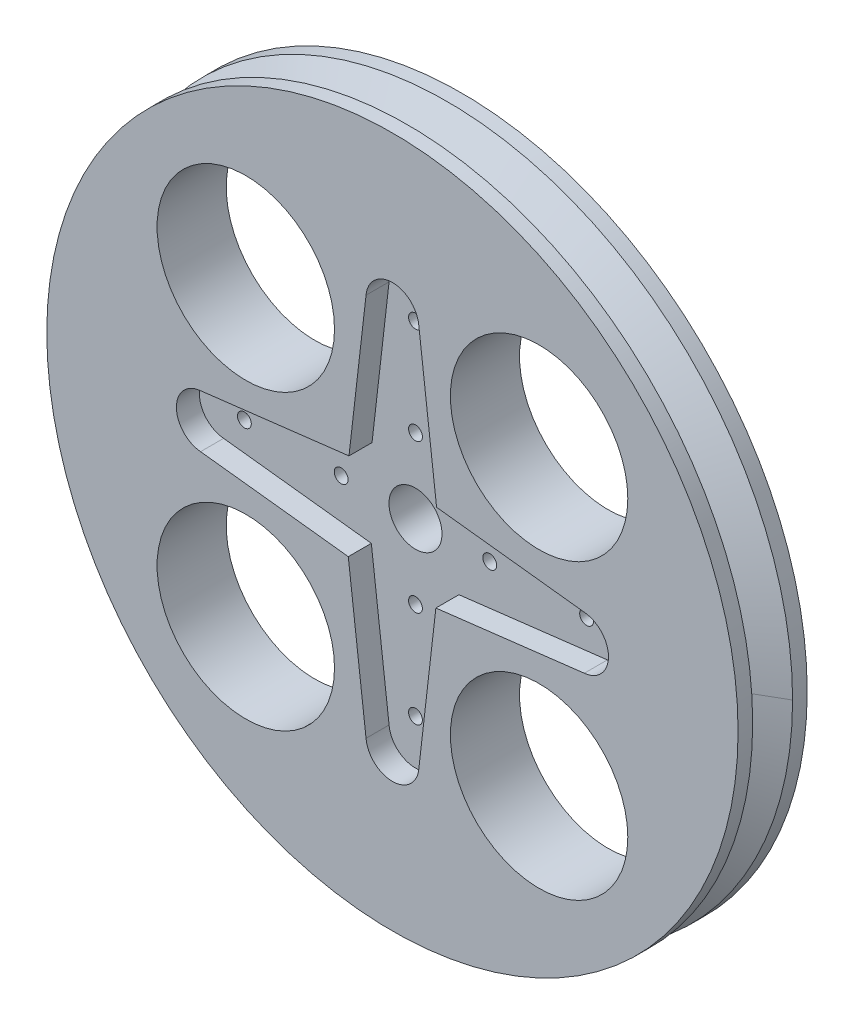
from build123d import *

# Parameters (mm, degrees)
SKETCH1_R           = 30
SKETCH1_R_2         = 7.7
SKETCH1_R_3         = 2.3
SKETCH1_R_4         = 0.6
BOSS_EXTRUDE1_DEPTH = 6
CUT_EXTRUDE1_DEPTH  = 2


with BuildPart() as part:
    # Sketch1 → Boss-Extrude1 (new body)
    with BuildSketch(Plane.XY):
        Circle(SKETCH1_R)
        with Locations((-12.727922061, 12.727922061)):
            Circle(SKETCH1_R_2, mode=Mode.SUBTRACT)
        with Locations((12.727922061, 12.727922061)):
            Circle(SKETCH1_R_2, mode=Mode.SUBTRACT)
        with Locations((12.727922061, -12.727922061)):
            Circle(SKETCH1_R_2, mode=Mode.SUBTRACT)
        with Locations((-12.727922061, -12.727922061)):
            Circle(SKETCH1_R_2, mode=Mode.SUBTRACT)
        Circle(SKETCH1_R_3, mode=Mode.SUBTRACT)
        with Locations((-14.85, 0)):
            Circle(SKETCH1_R_4, mode=Mode.SUBTRACT)
        with Locations((6.45, 0)):
            Circle(SKETCH1_R_4, mode=Mode.SUBTRACT)
        with Locations((0, -6.45)):
            Circle(SKETCH1_R_4, mode=Mode.SUBTRACT)
        with Locations((-6.45, 0)):
            Circle(SKETCH1_R_4, mode=Mode.SUBTRACT)
        with Locations((0, 6.45)):
            Circle(SKETCH1_R_4, mode=Mode.SUBTRACT)
        with Locations((0, 14.85)):
            Circle(SKETCH1_R_4, mode=Mode.SUBTRACT)
        with Locations((14.85, 0)):
            Circle(SKETCH1_R_4, mode=Mode.SUBTRACT)
        with Locations((0, -14.85)):
            Circle(SKETCH1_R_4, mode=Mode.SUBTRACT)
    extrude(amount=-BOSS_EXTRUDE1_DEPTH)

    # Cut-Sweep1: sweep along a curve in space
    with BuildLine() as cut_sweep1_path:
        ThreePointArc((30, 0, -6), (21.213203436, 21.213203436, -6), (0, 30, -6))
        ThreePointArc((0, 30, -6), (-21.213203436, 21.213203436, -6), (-30, 0, -6))
        ThreePointArc((-30, 0, -6), (-21.213203436, -21.213203436, -6), (0, -30, -6))
        ThreePointArc((0, -30, -6), (21.213203436, -21.213203436, -6), (30, 0, -6))
    # Sketch2 → Cut-Sweep1 (sweep, cut)
    with BuildSketch(Plane(origin=(0, 0, 0), x_dir=(1, 0, 0), z_dir=(0, 1, 0))):
        Polygon((-31.156921938, 0.6), (-27, 3), (-31.156921938, 5.4), align=None)
    sweep(path=cut_sweep1_path.line, mode=Mode.SUBTRACT)

    # Sketch4 → Cut-Extrude1 (cut)
    with BuildSketch(Plane.XY):
        with BuildLine():
            Line((-3.770723751, 3.831893278), (-16.652735562, 2.291047422))
            ThreePointArc((-16.652735562, 2.291047422), (-18.75, 0), (-16.652735562, -2.291047422))
            Line((-16.652735562, -2.291047422), (-3.831893278, -3.770723751))
            Line((-3.831893278, -3.770723751), (-2.291047422, -16.652735562))
            ThreePointArc((-2.291047422, -16.652735562), (0, -18.75), (2.291047422, -16.652735562))
            Line((2.291047422, -16.652735562), (3.770723751, -3.831893278))
            Line((3.770723751, -3.831893278), (16.652735562, -2.291047422))
            ThreePointArc((16.652735562, -2.291047422), (18.75, 0), (16.652735562, 2.291047422))
            Line((16.652735562, 2.291047422), (3.831893278, 3.770723751))
            Line((3.831893278, 3.770723751), (2.291047422, 16.652735562))
            ThreePointArc((2.291047422, 16.652735562), (0, 18.75), (-2.291047422, 16.652735562))
            Line((-2.291047422, 16.652735562), (-3.770723751, 3.831893278))
        make_face()
    extrude(amount=-CUT_EXTRUDE1_DEPTH, mode=Mode.SUBTRACT)


solid = part.part
